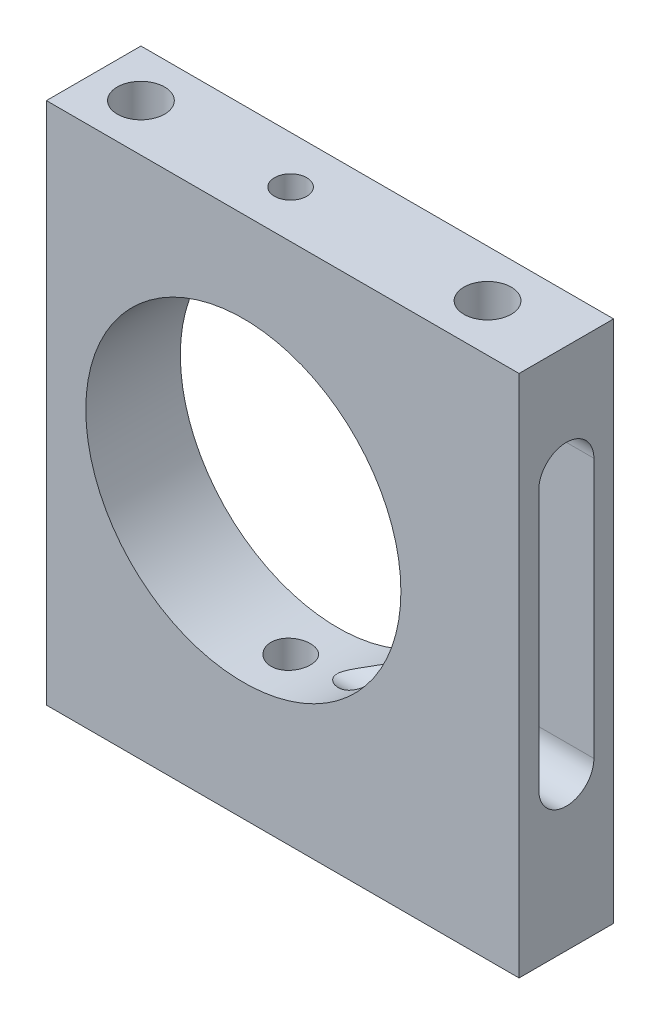
from build123d import *

# Parameters (mm, degrees)
SKETCH1_W                     = 35
SKETCH1_H                     = 33.23
SKETCH1_R                     = 10
BOSS_EXTRUDE1_DEPTH           = 6
CUT_EXTRUDE1_DEPTH            = 16
F_3_0MM_DOWEL_HOLE1_D         = 3
F_3_0MM_DOWEL_HOLE1_DEPTH     = 7.2
F_3_0MM_DOWEL_HOLE1_TIP       = 0.901290929
SKETCH9_W                     = 6
SKETCH9_H                     = 33.23
CUT_EXTRUDE2_DEPTH            = 5
M2_5X0_45_TAPPED_HOLE1_REACH  = 40.033
M2_5X0_45_TAPPED_HOLE1_BORE_R = 1.025
M3X0_5_TAPPED_HOLE2_REACH     = 40.033
M3X0_5_TAPPED_HOLE2_BORE_R    = 1.25


with BuildPart() as part:
    # Sketch1 → Boss-Extrude1 (new body)
    with BuildSketch(Plane.XY):
        with Locations((0, -0.885)):
            Rectangle(SKETCH1_W, SKETCH1_H)
        Circle(SKETCH1_R, mode=Mode.SUBTRACT)
    extrude(amount=BOSS_EXTRUDE1_DEPTH)

    # Sketch2 → Cut-Extrude1 (cut)
    with BuildSketch(Plane(origin=(17.5, 0, 0), x_dir=(0, 0, -1), z_dir=(1, 0, 0))):
        with BuildLine():
            Line((-4.75, -7.806071268), (-4.75, 8.693928732))
            ThreePointArc((-4.75, 8.693928732), (-3, 10.443928732), (-1.25, 8.693928732))
            Line((-1.25, 8.693928732), (-1.25, -7.806071268))
            ThreePointArc((-1.25, -7.806071268), (-3, -9.556071268), (-4.75, -7.806071268))
        make_face()
    extrude(amount=-CUT_EXTRUDE1_DEPTH, mode=Mode.SUBTRACT)

    # Ø3.0mm Dowel Hole1
    with Locations(Plane(origin=(0, 15.73, 0), x_dir=(1, 0, 0), z_dir=(0, 1, 0))):
        with Locations((-9.5, -3), (12.5, -3)):
            Hole(F_3_0MM_DOWEL_HOLE1_D / 2, depth=F_3_0MM_DOWEL_HOLE1_DEPTH)
            with Locations((0, 0, -(F_3_0MM_DOWEL_HOLE1_DEPTH + F_3_0MM_DOWEL_HOLE1_TIP / 2))):  # 118° drill point
                Cone(0, F_3_0MM_DOWEL_HOLE1_D / 2, F_3_0MM_DOWEL_HOLE1_TIP, mode=Mode.SUBTRACT)

    # Sketch9 → Cut-Extrude2 (cut)
    with BuildSketch(Plane.ZY.offset(17.5)):
        with Locations((3, -0.885)):
            Rectangle(SKETCH9_W, SKETCH9_H)
    extrude(amount=-CUT_EXTRUDE2_DEPTH, mode=Mode.SUBTRACT)

    # M2.5x0.45 Tapped Hole1 bore → M2.5x0.45 Tapped Hole1 (cut, up to next)
    with BuildSketch(Plane(origin=(0, 15.73, 0), x_dir=(1, 0, 0), z_dir=(0, 1, 0)), mode=Mode.PRIVATE) as m2_5x0_45_tapped_hole1_sk1:
        with Locations((0, -3)):
            Circle(M2_5X0_45_TAPPED_HOLE1_BORE_R)
    m2_5x0_45_tapped_hole1_tool1 = extrude(m2_5x0_45_tapped_hole1_sk1.sketch, amount=-M2_5X0_45_TAPPED_HOLE1_REACH, mode=Mode.PRIVATE) & part.part
    add(m2_5x0_45_tapped_hole1_tool1.solids().sort_by_distance((0, 15.73, 3))[0], mode=Mode.SUBTRACT)

    # M3x0.5 Tapped Hole2 bore → M3x0.5 Tapped Hole2 (cut, up to next)
    with BuildSketch(Plane(origin=(0, -17.5, 0), x_dir=(-1, 0, 0), z_dir=(0, -1, 0)), mode=Mode.PRIVATE) as m3x0_5_tapped_hole2_sk1:
        with Locations((0, -2.990437558)):
            Circle(M3X0_5_TAPPED_HOLE2_BORE_R)
    m3x0_5_tapped_hole2_tool1 = extrude(m3x0_5_tapped_hole2_sk1.sketch, amount=-M3X0_5_TAPPED_HOLE2_REACH, mode=Mode.PRIVATE) & part.part
    add(m3x0_5_tapped_hole2_tool1.solids().sort_by_distance((0, -17.5, 2.990438))[0], mode=Mode.SUBTRACT)


solid = part.part
